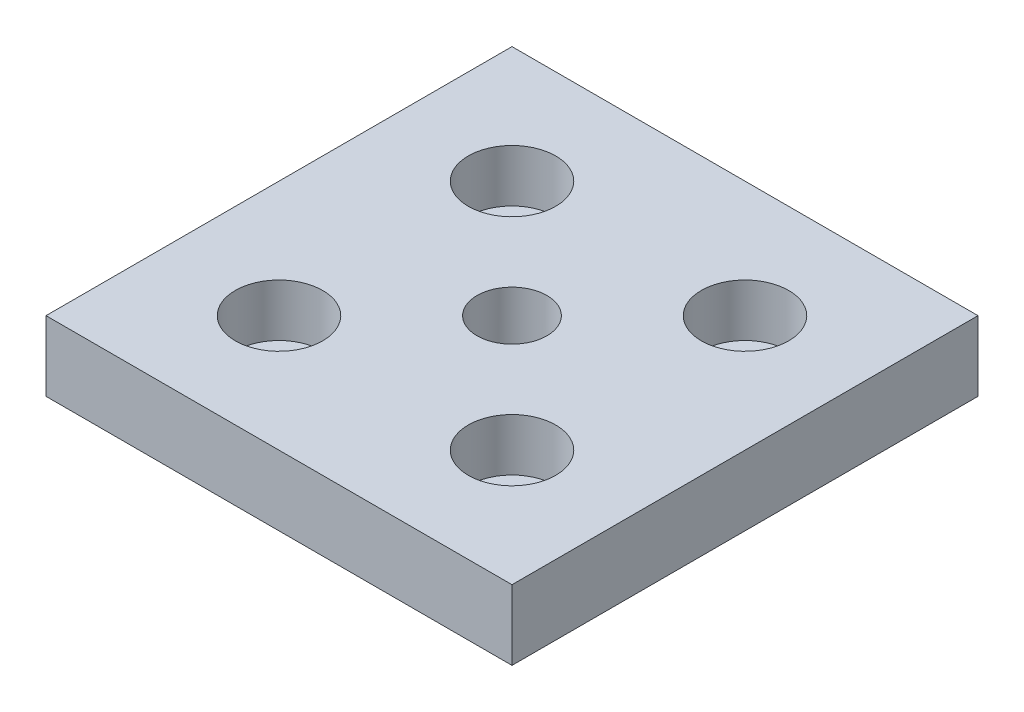
from build123d import *

# Parameters (mm, degrees)
SKETCH_1_W             = 80
SKETCH_1_H             = 80
EXTRUDE_1_DEPTH        = 12
HOLE_WIZARD_M141_D     = 12
HOLE_WIZARD_M141_DEPTH = 12
SKETCH_12_R            = 4.5
CUT_EXTRUDE_1_DEPTH    = 13
SKETCH_13_R            = 7.5
CUT_EXTRUDE_2_DEPTH    = 9


with BuildPart() as part:
    # Эскиз1 → Бобышка-Вытянуть1 (new body)
    with BuildSketch(Plane(origin=(0, 0, 0), x_dir=(1, 0, 0), z_dir=(0, 1, 0))):
        Rectangle(SKETCH_1_W, SKETCH_1_H)
    extrude(amount=EXTRUDE_1_DEPTH)

    # Отверстие обработанное метчиком M141
    with Locations(Plane(origin=(0, 12, 0), x_dir=(1, 0, 0), z_dir=(0, 1, 0))):
        with Locations((0, 0)):
            Hole(HOLE_WIZARD_M141_D / 2, depth=HOLE_WIZARD_M141_DEPTH)

    # Эскиз12 → Вырез-Вытянуть1 (cut, through all)
    with BuildSketch(Plane(origin=(0, 12, 0), x_dir=(1, 0, 0), z_dir=(0, 1, 0))):
        with Locations(Location((-20, 20, 0), (0, 0, 270))):  # turned: the seam where the file's is
            Circle(SKETCH_12_R)
        with Locations(Location((20, 20, 0), (0, 0, 270))):  # turned: the seam where the file's is
            Circle(SKETCH_12_R)
        with Locations(Location((20, -20, 0), (0, 0, 270))):  # turned: the seam where the file's is
            Circle(SKETCH_12_R)
        with Locations(Location((-20, -20, 0), (0, 0, 270))):  # turned: the seam where the file's is
            Circle(SKETCH_12_R)
    extrude(amount=-CUT_EXTRUDE_1_DEPTH, mode=Mode.SUBTRACT)

    # Эскиз13 → Вырез-Вытянуть2 (cut)
    with BuildSketch(Plane(origin=(0, 12, 0), x_dir=(1, 0, 0), z_dir=(0, 1, 0))):
        with Locations(Location((-20, 20, 0), (0, 0, 270))):  # turned: the seam where the file's is
            Circle(SKETCH_13_R)
        with Locations(Location((20, 20, 0), (0, 0, 270))):  # turned: the seam where the file's is
            Circle(SKETCH_13_R)
        with Locations(Location((20, -20, 0), (0, 0, 270))):  # turned: the seam where the file's is
            Circle(SKETCH_13_R)
        with Locations(Location((-20, -20, 0), (0, 0, 270))):  # turned: the seam where the file's is
            Circle(SKETCH_13_R)
    extrude(amount=-CUT_EXTRUDE_2_DEPTH, mode=Mode.SUBTRACT)


solid = part.part
